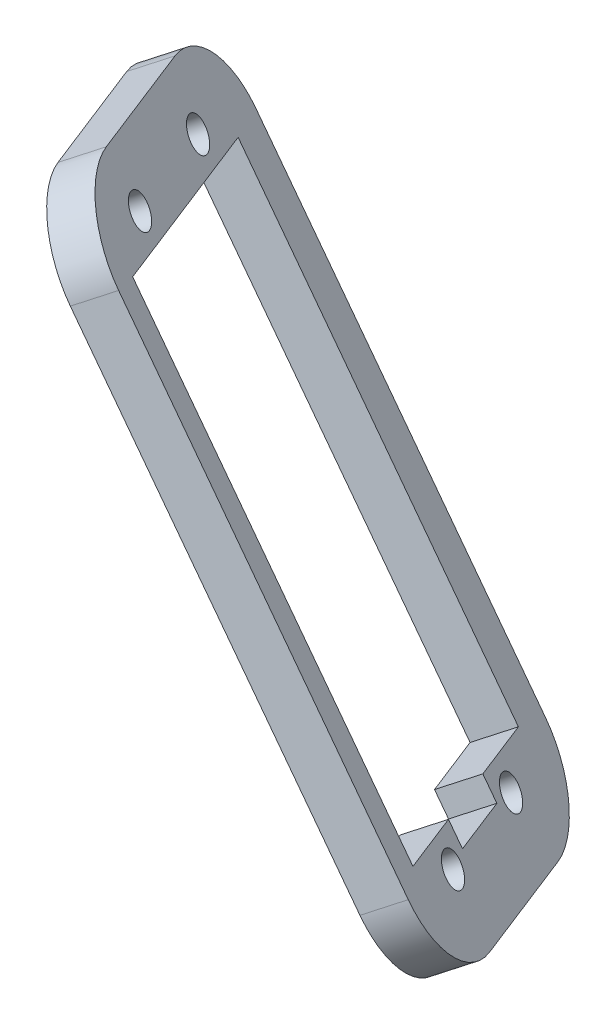
from build123d import *

# Parameters (mm, degrees)
BOSS_EXTRUDE1_DEPTH = 5
SKETCH2_R           = 2
CUT_EXTRUDE1_DEPTH  = 10
FILLET1_R           = 10


with BuildPart() as part:
    # Sketch1 → Boss-Extrude1 (new body)
    with BuildSketch(Plane(origin=(-134.331980559, -86.262659899, 84.991923549), x_dir=(0.395424411, 0.253925843, 0.882701083), z_dir=(-0.742744505, -0.476961006, 0.469934888))):
        Polygon((-449.960059364, 72.073536166), (-410.158714417, 68.091961048), (-418.320943409, -13.500796093), (-458.122288356, -9.519220975), align=None)
        Polygon((-431.102989517, -0.46855114), (-420.804391512, -1.498783702), (-414.832028835, 58.203233718), (-445.379561081, 61.259092621), (-451.351923758, 1.557075201), (-441.053325753, 0.526842639), (-441.351943887, -2.458258232), (-431.40160765, -3.453652011), align=None, mode=Mode.SUBTRACT)
    extrude(amount=BOSS_EXTRUDE1_DEPTH)

    # Sketch2 → Cut-Extrude1 (cut)
    with BuildSketch(Plane(origin=(-138.045703084, -88.647464931, 87.341597987), x_dir=(0.395424411, 0.253925843, 0.882701083), z_dir=(-0.742744505, -0.476961006, 0.469934888))):
        with Locations((-444.834579578, -2.61236419)):
            Circle(SKETCH2_R)
        with Locations((-428.018511338, -4.294579677)):
            Circle(SKETCH2_R)
        with Locations((-438.165441255, 64.054888596)):
            Circle(SKETCH2_R)
        with Locations((-421.349373015, 62.372673109)):
            Circle(SKETCH2_R)
    extrude(amount=-CUT_EXTRUDE1_DEPTH, mode=Mode.SUBTRACT)

    # Fillet1
    fillet1_edges = [part.edges().sort_by_distance(p)[0] for p in [
        (-353.05843578, -141.065625808, -311.013470799),
        (-335.168597716, -134.309312615, -275.880780522),
        (-294.308099004, -205.037739583, -283.08558889),
        (-312.197937067, -211.794052776, -318.218279167),
    ]]
    fillet(fillet1_edges, radius=FILLET1_R)


solid = part.part
